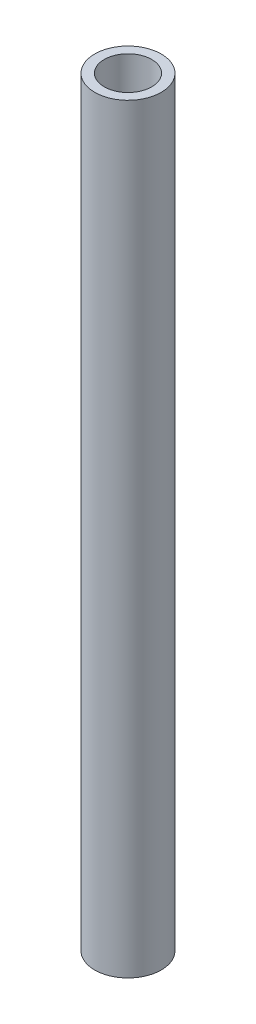
from build123d import *

# Parameters (mm, degrees)
SKETCH_1_R      = 3.5
SKETCH_1_R_2    = 2.5
EXTRUDE_1_DEPTH = 40


with BuildPart() as part:
    # 草图1 → 凸台-拉伸1 (new body, symmetric)
    with BuildSketch(Plane(origin=(0, 0, 0), x_dir=(1, 0, 0), z_dir=(0, 1, 0))):
        Circle(SKETCH_1_R)
        Circle(SKETCH_1_R_2, mode=Mode.SUBTRACT)
    extrude(amount=EXTRUDE_1_DEPTH, both=True)


solid = part.part
